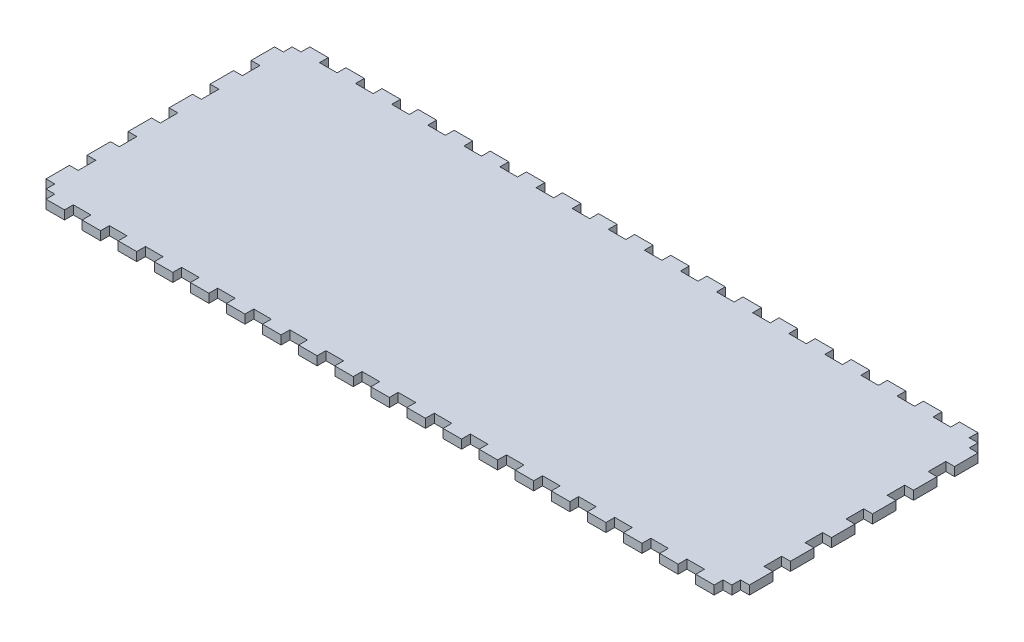
from build123d import *

# Parameters (mm, degrees)
SKETCH1_W           = 508
SKETCH1_H           = 190.5
BOSS_EXTRUDE1_DEPTH = 6.35
SKETCH2_W           = 508
SKETCH2_H           = 190.5
SKETCH2_W_2         = 495.3
SKETCH2_H_2         = 177.8
BOSS_EXTRUDE2_DEPTH = 298.45
SKETCH3_W           = 6.35
SKETCH3_H           = 16.933333333
SKETCH3_H_2         = 16.933333334
CUT_EXTRUDE1_DEPTH  = 12.7
SKETCH4_W           = 6.35
SKETCH4_H           = 15.875
CUT_EXTRUDE2_DEPTH  = 6.35
SKETCH6_W           = 631.817103759
SKETCH6_H           = 334.675396546
CUT_EXTRUDE3_DEPTH  = 191.5
SKETCH5_W           = 6.35
SKETCH5_H           = 6.35
SKETCH5_H_2         = 12.7
SKETCH5_W_2         = 12.7
CUT_EXTRUDE4_DEPTH  = 7.35


with BuildPart() as part:
    # Sketch1 → Boss-Extrude1 (new body)
    with BuildSketch(Plane(origin=(0, 0, 0), x_dir=(1, 0, 0), z_dir=(0, 1, 0))):
        Rectangle(SKETCH1_W, SKETCH1_H)
    extrude(amount=BOSS_EXTRUDE1_DEPTH)

    # Sketch2 → Boss-Extrude2 (add)
    with BuildSketch(Plane(origin=(0, 6.35, 0), x_dir=(1, 0, 0), z_dir=(0, 1, 0))):
        Rectangle(SKETCH2_W, SKETCH2_H)
        Rectangle(SKETCH2_W_2, SKETCH2_H_2, mode=Mode.SUBTRACT)
    extrude(amount=BOSS_EXTRUDE2_DEPTH)

    # Sketch3 → Cut-Extrude1 (cut)
    with BuildSketch(Plane.XY.offset(95.25)):
        with BuildLine():
            Line((-3.302, 283.21), (-3.302, 6.35))
            Line((-3.302, 6.35), (3.302, 6.35))
            Line((3.302, 6.35), (3.302, 292.354))
            Line((3.302, 292.354), (-16.256, 292.354))
            Line((-16.256, 292.354), (-16.256, 285.75))
            Line((-16.256, 285.75), (-5.842, 285.75))
            ThreePointArc((-5.842, 285.75), (-4.045948776, 285.006051224), (-3.302, 283.21))
        make_face()
        with Locations((12.827, 80.433333334)):
            Rectangle(SKETCH3_W, SKETCH3_H)
        with Locations((12.827, 50.8)):
            Rectangle(SKETCH3_W, SKETCH3_H_2)
        with Locations((12.827, 21.166666667)):
            Rectangle(SKETCH3_W, SKETCH3_H)
    extrude(amount=-CUT_EXTRUDE1_DEPTH, mode=Mode.SUBTRACT)

    # Sketch4 → Cut-Extrude2 (cut)
    with BuildSketch(Plane.XY.offset(-88.9)):
        with Locations((-19.431, 284.1625)):
            Rectangle(SKETCH4_W, SKETCH4_H)
        with Locations((-19.431, 255.5875)):
            Rectangle(SKETCH4_W, SKETCH4_H)
        with Locations((-19.431, 227.0125)):
            Rectangle(SKETCH4_W, SKETCH4_H)
        with Locations((-19.431, 198.4375)):
            Rectangle(SKETCH4_W, SKETCH4_H)
        with Locations((-19.431, 169.8625)):
            Rectangle(SKETCH4_W, SKETCH4_H)
        with Locations((-19.431, 141.2875)):
            Rectangle(SKETCH4_W, SKETCH4_H)
        with Locations((-19.431, 112.7125)):
            Rectangle(SKETCH4_W, SKETCH4_H)
        with Locations((-19.431, 84.1375)):
            Rectangle(SKETCH4_W, SKETCH4_H)
        with Locations((-19.431, 55.5625)):
            Rectangle(SKETCH4_W, SKETCH4_H)
        with Locations((-19.431, 26.9875)):
            Rectangle(SKETCH4_W, SKETCH4_H)
    cut_extrude2 = extrude(amount=-CUT_EXTRUDE2_DEPTH, mode=Mode.SUBTRACT)

    # Mirror1: Cut-Extrude2 across plane
    add(cut_extrude2.mirror(Plane.ZY.offset(6.477)), mode=Mode.SUBTRACT)

    # Sketch6 → Cut-Extrude3 (cut, through all)
    with BuildSketch(Plane.XY.offset(95.25)):
        with Locations((10.426024815, 173.687698273)):
            Rectangle(SKETCH6_W, SKETCH6_H)
    extrude(amount=-CUT_EXTRUDE3_DEPTH, mode=Mode.SUBTRACT)

    # Sketch5 → Cut-Extrude4 (cut, through all)
    with BuildSketch(Plane(origin=(0, 0, 0), x_dir=(-1, 0, 0), z_dir=(0, -1, 0))):
        with Locations((244.475, -92.075)):
            Rectangle(SKETCH5_W, SKETCH5_H)
        with Locations((250.825, -92.075)):
            Rectangle(SKETCH5_W, SKETCH5_H)
        with Locations((250.825, -85.725)):
            Rectangle(SKETCH5_W, SKETCH5_H)
        with Locations((250.825, -59.266666667)):
            Rectangle(SKETCH5_W, SKETCH5_H_2)
        with Locations((250.825, -29.633333333)):
            Rectangle(SKETCH5_W, SKETCH5_H_2)
        with Locations((250.825, 0)):
            Rectangle(SKETCH5_W, SKETCH5_H_2)
        with Locations((250.825, 29.633333333)):
            Rectangle(SKETCH5_W, SKETCH5_H_2)
        with Locations((250.825, 59.266666667)):
            Rectangle(SKETCH5_W, SKETCH5_H_2)
        with Locations((250.825, 85.725)):
            Rectangle(SKETCH5_W, SKETCH5_H)
        with Locations((250.825, 92.075)):
            Rectangle(SKETCH5_W, SKETCH5_H)
        with Locations((244.475, 92.075)):
            Rectangle(SKETCH5_W, SKETCH5_H)
        with Locations((221.581578947, 92.075)):
            Rectangle(SKETCH5_W_2, SKETCH5_H)
        with Locations((195.513157895, 92.075)):
            Rectangle(SKETCH5_W_2, SKETCH5_H)
        with Locations((169.444736842, 92.075)):
            Rectangle(SKETCH5_W_2, SKETCH5_H)
        with Locations((143.376315789, 92.075)):
            Rectangle(SKETCH5_W_2, SKETCH5_H)
        with Locations((117.307894737, 92.075)):
            Rectangle(SKETCH5_W_2, SKETCH5_H)
        with Locations((91.239473684, 92.075)):
            Rectangle(SKETCH5_W_2, SKETCH5_H)
        with Locations((65.171052632, 92.075)):
            Rectangle(SKETCH5_W_2, SKETCH5_H)
        with Locations((39.102631579, 92.075)):
            Rectangle(SKETCH5_W_2, SKETCH5_H)
        with Locations((13.034210526, 92.075)):
            Rectangle(SKETCH5_W_2, SKETCH5_H)
        with Locations((-13.034210526, 92.075)):
            Rectangle(SKETCH5_W_2, SKETCH5_H)
        with Locations((-39.102631579, 92.075)):
            Rectangle(SKETCH5_W_2, SKETCH5_H)
        with Locations((-65.171052632, 92.075)):
            Rectangle(SKETCH5_W_2, SKETCH5_H)
        with Locations((-91.239473684, 92.075)):
            Rectangle(SKETCH5_W_2, SKETCH5_H)
        with Locations((-117.307894737, 92.075)):
            Rectangle(SKETCH5_W_2, SKETCH5_H)
        with Locations((-143.376315789, 92.075)):
            Rectangle(SKETCH5_W_2, SKETCH5_H)
        with Locations((-169.444736842, 92.075)):
            Rectangle(SKETCH5_W_2, SKETCH5_H)
        with Locations((-195.513157895, 92.075)):
            Rectangle(SKETCH5_W_2, SKETCH5_H)
        with Locations((195.513157895, -92.075)):
            Rectangle(SKETCH5_W_2, SKETCH5_H)
        with Locations((169.444736842, -92.075)):
            Rectangle(SKETCH5_W_2, SKETCH5_H)
        with Locations((143.376315789, -92.075)):
            Rectangle(SKETCH5_W_2, SKETCH5_H)
        with Locations((91.239473684, -92.075)):
            Rectangle(SKETCH5_W_2, SKETCH5_H)
        with Locations((65.171052632, -92.075)):
            Rectangle(SKETCH5_W_2, SKETCH5_H)
        with Locations((221.581578947, -92.075)):
            Rectangle(SKETCH5_W_2, SKETCH5_H)
        with Locations((117.307894737, -92.075)):
            Rectangle(SKETCH5_W_2, SKETCH5_H)
        with Locations((39.102631579, -92.075)):
            Rectangle(SKETCH5_W_2, SKETCH5_H)
        with Locations((13.034210526, -92.075)):
            Rectangle(SKETCH5_W_2, SKETCH5_H)
        with Locations((-65.171052632, -92.075)):
            Rectangle(SKETCH5_W_2, SKETCH5_H)
        with Locations((-91.239473684, -92.075)):
            Rectangle(SKETCH5_W_2, SKETCH5_H)
        with Locations((-117.307894737, -92.075)):
            Rectangle(SKETCH5_W_2, SKETCH5_H)
        with Locations((-143.376315789, -92.075)):
            Rectangle(SKETCH5_W_2, SKETCH5_H)
        with Locations((-195.513157895, -92.075)):
            Rectangle(SKETCH5_W_2, SKETCH5_H)
        with Locations((-221.581578947, -92.075)):
            Rectangle(SKETCH5_W_2, SKETCH5_H)
        with Locations((-244.475, -92.075)):
            Rectangle(SKETCH5_W, SKETCH5_H)
        with Locations((-250.825, -92.075)):
            Rectangle(SKETCH5_W, SKETCH5_H)
        with Locations((-250.825, -85.725)):
            Rectangle(SKETCH5_W, SKETCH5_H)
        with Locations((-250.825, -59.266666667)):
            Rectangle(SKETCH5_W, SKETCH5_H_2)
        with Locations((-250.825, -29.633333333)):
            Rectangle(SKETCH5_W, SKETCH5_H_2)
        with Locations((-250.825, 0)):
            Rectangle(SKETCH5_W, SKETCH5_H_2)
        with Locations((-250.825, 29.633333333)):
            Rectangle(SKETCH5_W, SKETCH5_H_2)
        with Locations((-250.825, 59.266666667)):
            Rectangle(SKETCH5_W, SKETCH5_H_2)
        with Locations((-250.825, 85.725)):
            Rectangle(SKETCH5_W, SKETCH5_H)
        with Locations((-250.825, 92.075)):
            Rectangle(SKETCH5_W, SKETCH5_H)
        with Locations((-244.475, 92.075)):
            Rectangle(SKETCH5_W, SKETCH5_H)
        with Locations((-221.581578947, 92.075)):
            Rectangle(SKETCH5_W_2, SKETCH5_H)
        with Locations((-13.034210526, -92.075)):
            Rectangle(SKETCH5_W_2, SKETCH5_H)
        with Locations((-39.102631579, -92.075)):
            Rectangle(SKETCH5_W_2, SKETCH5_H)
        with Locations((-169.444736842, -92.075)):
            Rectangle(SKETCH5_W_2, SKETCH5_H)
    extrude(amount=-CUT_EXTRUDE4_DEPTH, mode=Mode.SUBTRACT)


solid = part.part
